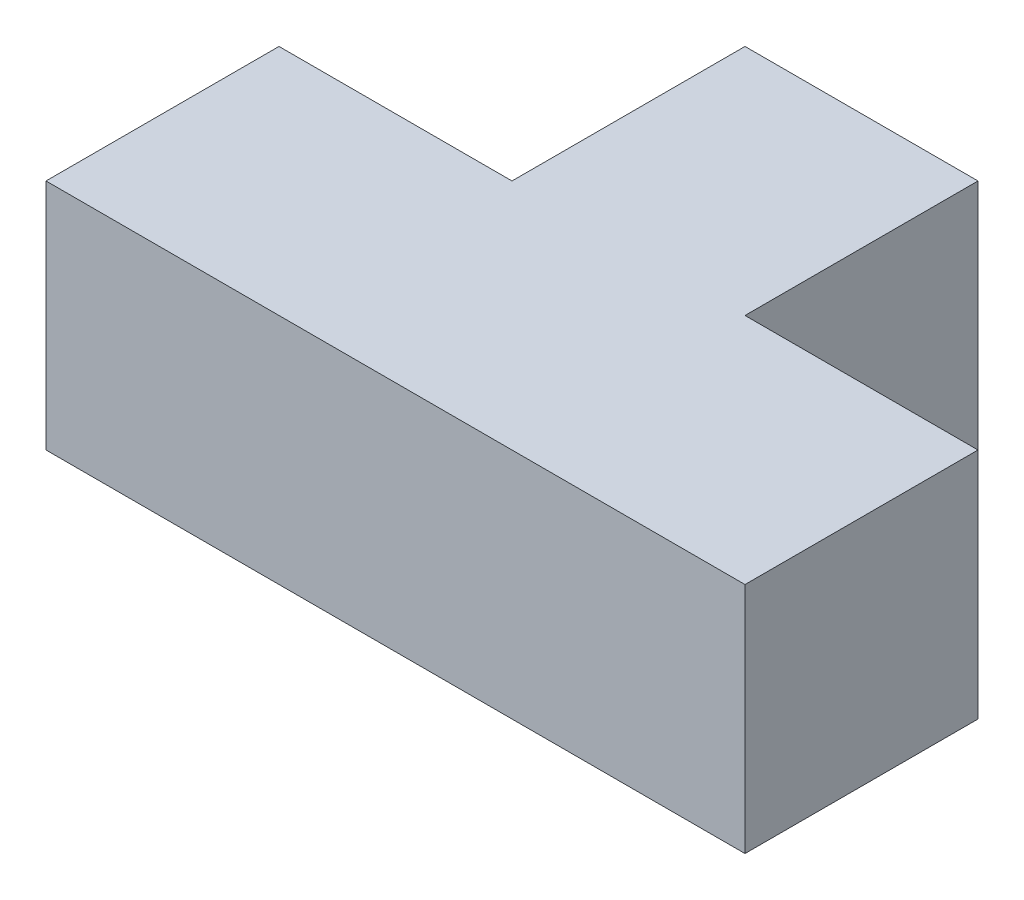
from build123d import *

# Parameters (mm, degrees)
SALIENTE_EXTRUIR1_DEPTH = 200


with BuildPart() as part:
    # Croquis1 → Saliente-Extruir1 (new body)
    with BuildSketch(Plane(origin=(0, 0, 0), x_dir=(1, 0, 0), z_dir=(0, 1, 0))):
        Polygon((400, 200), (600, 200), (600, 0), (0, 0), (0, 200), (200, 200), (200, 400), (400, 400), align=None)
    extrude(amount=SALIENTE_EXTRUIR1_DEPTH)


solid = part.part
